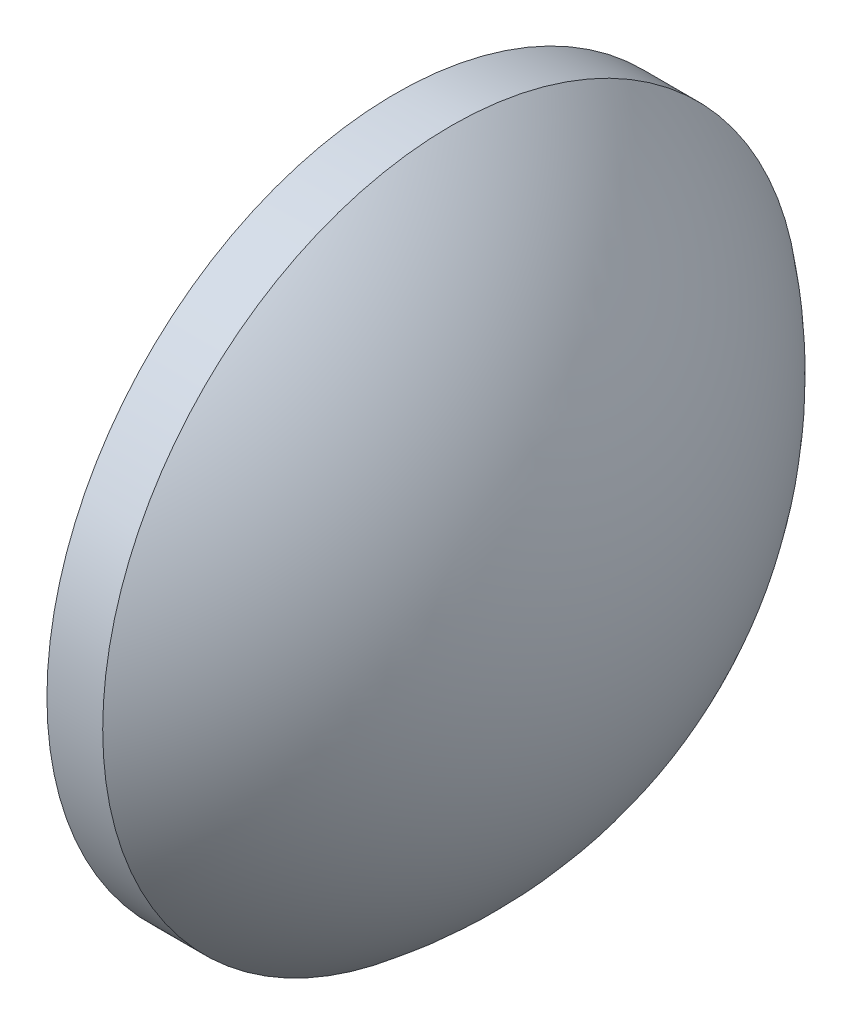
from build123d import *


with BuildPart() as part:
    # 草图1 → 旋转1 (revolve)
    with BuildSketch(Plane.XY):
        with BuildLine():
            Line((376.300901326, 56.89119272), (376.300901326, 64.39119272))
            Line((376.300901326, 64.39119272), (377.500901326, 64.39119272))
            ThreePointArc((377.500901326, 64.39119272), (380.225577485, 61.072699626), (381.200901326, 56.89119272))
            Line((381.200901326, 56.89119272), (376.300901326, 56.89119272))
        make_face()
    revolve(axis=Axis((373.460089195, 56.89119272, 0), (1, 0, 0)))


solid = part.part
